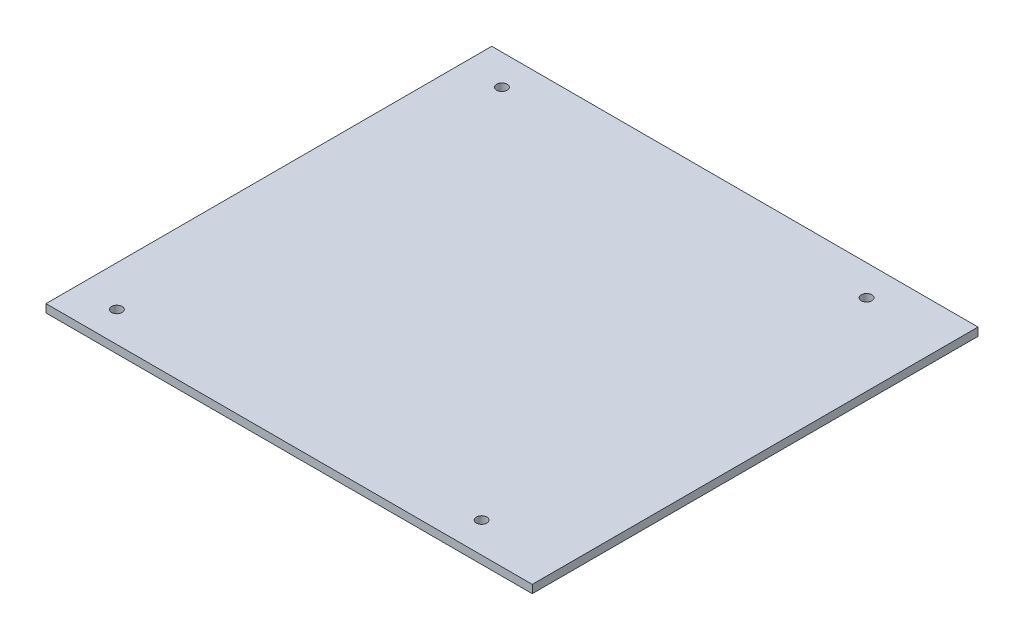
from build123d import *

# Parameters (mm, degrees)
SKETCH1_W                 = 152.4
SKETCH1_H                 = 139.7
BOSS_EXTRUDE1_DEPTH       = 2.54
M4X0_7_TAPPED_HOLE1_D     = 3.3
M4X0_7_TAPPED_HOLE1_DEPTH = 9.906


with BuildPart() as part:
    # Sketch1 → Boss-Extrude1 (new body)
    with BuildSketch(Plane(origin=(0, 0, 0), x_dir=(1, 0, 0), z_dir=(0, 1, 0))):
        Rectangle(SKETCH1_W, SKETCH1_H)
    extrude(amount=BOSS_EXTRUDE1_DEPTH)

    # M4x0.7 Tapped Hole1
    with Locations(Plane(origin=(0, 2.54, 0), x_dir=(1, 0, 0), z_dir=(0, 1, 0))):
        with Locations((-63.5, 60.325), (-63.5, -60.325), (50.8, -60.325), (50.8, 60.325)):
            Hole(M4X0_7_TAPPED_HOLE1_D / 2, depth=M4X0_7_TAPPED_HOLE1_DEPTH)


solid = part.part
